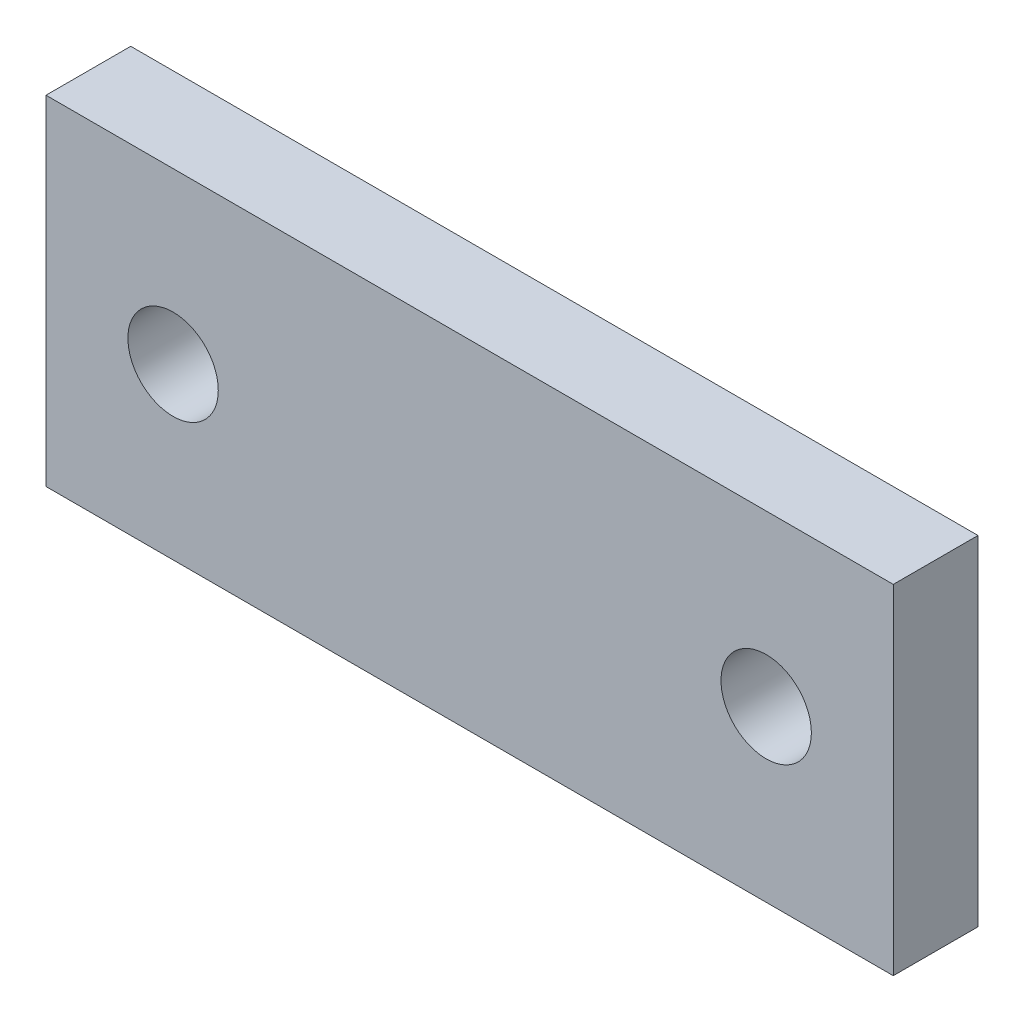
from build123d import *

# Parameters (mm, degrees)
SKETCH1_W           = 30
SKETCH1_H           = 12
SKETCH1_R           = 1.6
BOSS_EXTRUDE1_DEPTH = 3


with BuildPart() as part:
    # Sketch1 → Boss-Extrude1 (new body)
    with BuildSketch(Plane.XY):
        with Locations((9.719411157, 6)):
            Rectangle(SKETCH1_W, SKETCH1_H)
        with Locations((-0.780588843, 6)):
            Circle(SKETCH1_R, mode=Mode.SUBTRACT)
        with Locations((20.219411157, 6)):
            Circle(SKETCH1_R, mode=Mode.SUBTRACT)
    extrude(amount=BOSS_EXTRUDE1_DEPTH)


solid = part.part
